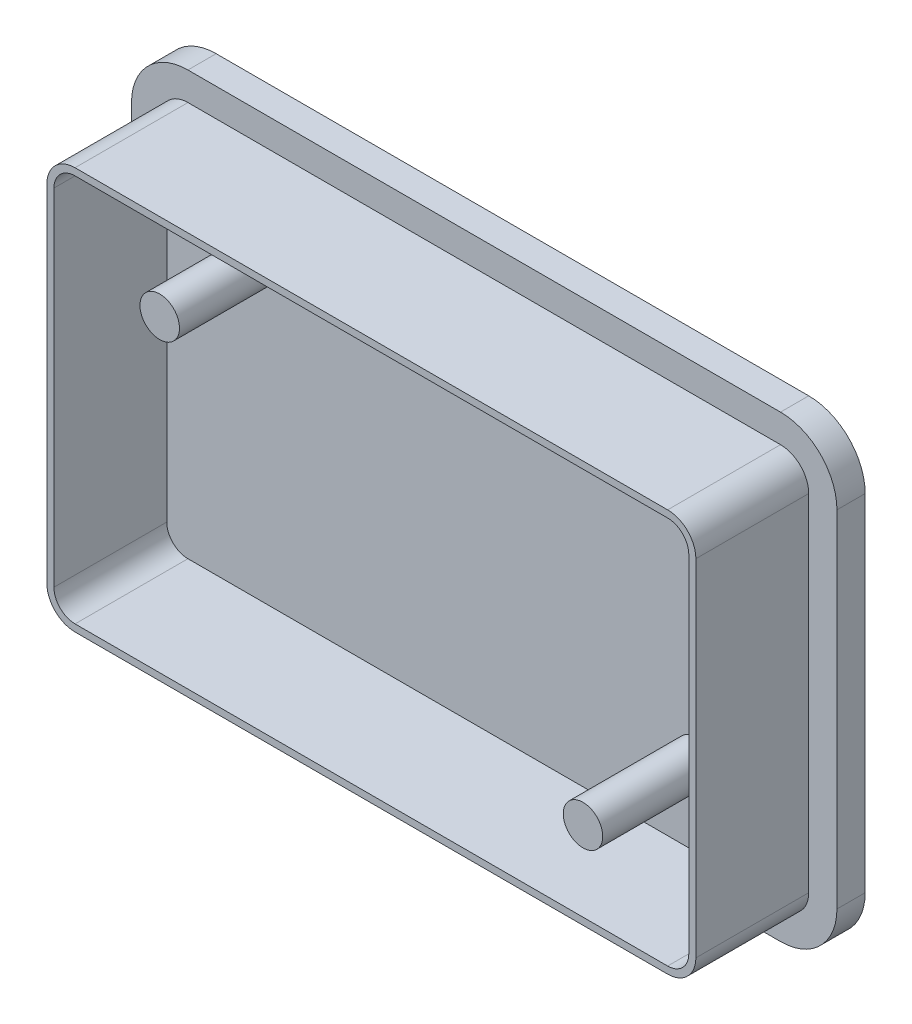
from build123d import *

# Parameters (mm, degrees)
BOSS_EXTRUDE1_DEPTH = 2
SKETCH1_3_R         = 1.4
BOSS_EXTRUDE2_DEPTH = 10


with BuildPart() as part:
    # Sketch1 → Boss-Extrude1 (new body)
    with BuildSketch(Plane.XY):
        with BuildLine():
            ThreePointArc((-25, -12.25), (-23.828427125, -15.078427125), (-21, -16.25))
            Line((-21, -16.25), (21, -16.25))
            ThreePointArc((21, -16.25), (23.828427125, -15.078427125), (25, -12.25))
            Line((25, -12.25), (25, 12.25))
            ThreePointArc((25, 12.25), (23.828427125, 15.078427125), (21, 16.25))
            Line((21, 16.25), (-21, 16.25))
            ThreePointArc((-21, 16.25), (-23.828427125, 15.078427125), (-25, 12.25))
            Line((-25, 12.25), (-25, -12.25))
        make_face()
    extrude(amount=BOSS_EXTRUDE1_DEPTH)

    # Sketch1_3 → Boss-Extrude2 (add)
    # profile 1 of 3: a face of its own
    with BuildSketch(Plane.XY):
        with BuildLine():
            Line((21, 14.25), (-21, 14.25))
            ThreePointArc((-21, 14.25), (-22.414213562, 13.664213562), (-23, 12.25))
            Line((-23, 12.25), (-23, -12.25))
            ThreePointArc((-23, -12.25), (-22.414213562, -13.664213562), (-21, -14.25))
            Line((-21, -14.25), (21, -14.25))
            ThreePointArc((21, -14.25), (22.414213562, -13.664213562), (23, -12.25))
            Line((23, -12.25), (23, 12.25))
            ThreePointArc((23, 12.25), (22.414213562, 13.664213562), (21, 14.25))
        make_face()
        with BuildLine():
            ThreePointArc((-22.5, 12.25), (-22.060660172, 13.310660172), (-21, 13.75))
            Line((-21, 13.75), (21, 13.75))
            ThreePointArc((21, 13.75), (22.060660172, 13.310660172), (22.5, 12.25))
            Line((22.5, 12.25), (22.5, -12.25))
            ThreePointArc((22.5, -12.25), (22.060660172, -13.310660172), (21, -13.75))
            Line((21, -13.75), (-21, -13.75))
            ThreePointArc((-21, -13.75), (-22.060660172, -13.310660172), (-22.5, -12.25))
            Line((-22.5, -12.25), (-22.5, 12.25))
        make_face(mode=Mode.SUBTRACT)
    # profile 2 of 3: a face of its own
    with BuildSketch(Plane.XY):
        with Locations((-15, 8.1)):
            Circle(SKETCH1_3_R)
    # profile 3 of 3: a face of its own
    with BuildSketch(Plane.XY):
        with Locations((15, -8.1)):
            Circle(SKETCH1_3_R)
    extrude(amount=BOSS_EXTRUDE2_DEPTH)


solid = part.part
